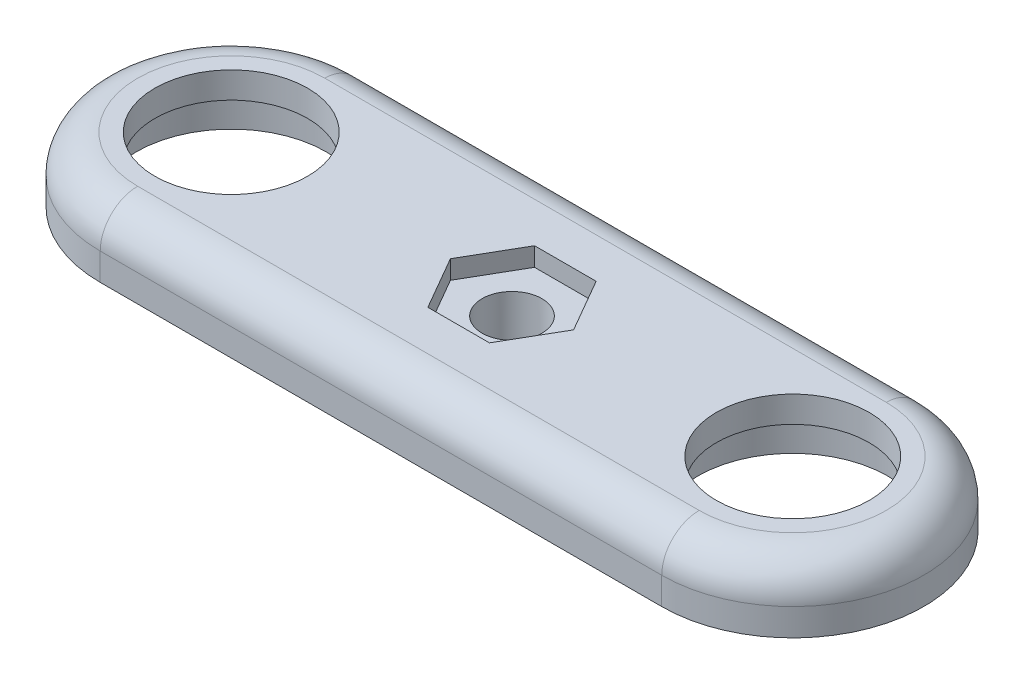
from build123d import *

# Parameters (mm, degrees)
SKETCH1_R           = 4.08
BOSS_EXTRUDE1_DEPTH = 3.45
SKETCH2_R           = 1.6
CUT_EXTRUDE1_DEPTH  = 3.45
CUT_EXTRUDE2_DEPTH  = 1
SKETCH4_R           = 5.08
CUT_EXTRUDE3_DEPTH  = 2.05
FILLET1_R           = 2


with BuildPart() as part:
    # Sketch1 → Boss-Extrude1 (new body)
    with BuildSketch(Plane(origin=(0, 0, 0), x_dir=(1, 0, 0), z_dir=(0, 1, 0))):
        with BuildLine():
            Line((-15, 7), (15, 7))
            ThreePointArc((15, 7), (22, 0), (15, -7))
            Line((15, -7), (-15, -7))
            ThreePointArc((-15, -7), (-22, 0), (-15, 7))
        make_face()
        with Locations((-15, 0)):
            Circle(SKETCH1_R, mode=Mode.SUBTRACT)
        with Locations((15, 0)):
            Circle(SKETCH1_R, mode=Mode.SUBTRACT)
    extrude(amount=BOSS_EXTRUDE1_DEPTH)

    # Sketch2 → Cut-Extrude1 (cut)
    with BuildSketch(Plane(origin=(0, 3.45, 0), x_dir=(1, 0, 0), z_dir=(0, 1, 0))):
        Circle(SKETCH2_R)
    extrude(amount=-CUT_EXTRUDE1_DEPTH, mode=Mode.SUBTRACT)

    # Sketch3 → Cut-Extrude2 (cut)
    with BuildSketch(Plane(origin=(0, 3.45, 0), x_dir=(1, 0, 0), z_dir=(0, 1, 0))):
        Polygon((-1.645448267, 2.85), (1.645448267, 2.85), (3.290896534, 0), (1.645448267, -2.85), (-1.645448267, -2.85), (-3.290896534, 0), align=None)
    extrude(amount=-CUT_EXTRUDE2_DEPTH, mode=Mode.SUBTRACT)

    # Sketch4 → Cut-Extrude3 (cut)
    with BuildSketch(Plane.XZ):
        with Locations((-15, 0)):
            Circle(SKETCH4_R)
        with Locations((15, 0)):
            Circle(SKETCH4_R)
    extrude(amount=-CUT_EXTRUDE3_DEPTH, mode=Mode.SUBTRACT)

    # Fillet1
    fillet1_edges = [part.edges().sort_by_distance(p)[0] for p in [
        (22, 3.45, 0),
        (0, 3.45, -7),
        (-22, 3.45, 0),
        (0, 3.45, 7),
    ]]
    fillet(fillet1_edges, radius=FILLET1_R)


solid = part.part
